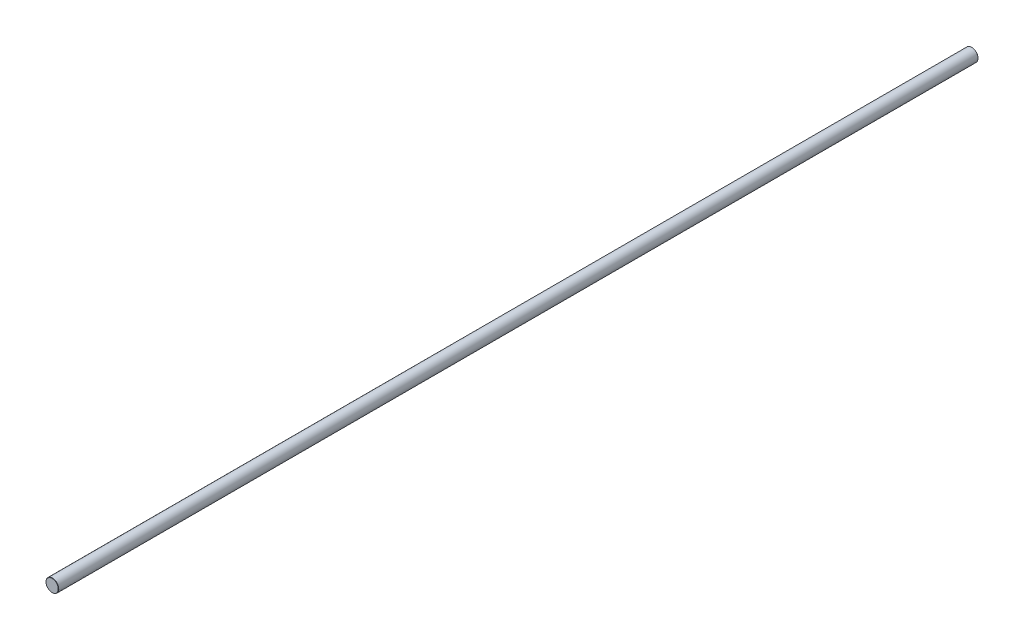
from build123d import *

# Parameters (mm, degrees)
SKETCH3_R                = 6.35
BOSS_EXTRUDE1_DEPTH      = 457.2
BOSS_EXTRUDE1_DEPTH_BACK = 457.2
CHAMFER1_SIZE            = 0.254


with BuildPart() as part:
    # Sketch3 → Boss-Extrude1 (new body, two sides)
    with BuildSketch(Plane.XY) as boss_extrude1_sk:
        Circle(SKETCH3_R)
    extrude(amount=BOSS_EXTRUDE1_DEPTH)
    extrude(boss_extrude1_sk.sketch, amount=-BOSS_EXTRUDE1_DEPTH_BACK)

    # Chamfer1
    chamfer1_edges = [part.edges().sort_by_distance(p)[0] for p in [
        (-6.35, 0, -457.2),
        (-6.35, 0, 457.2),
    ]]
    chamfer(chamfer1_edges, length=CHAMFER1_SIZE)


solid = part.part
